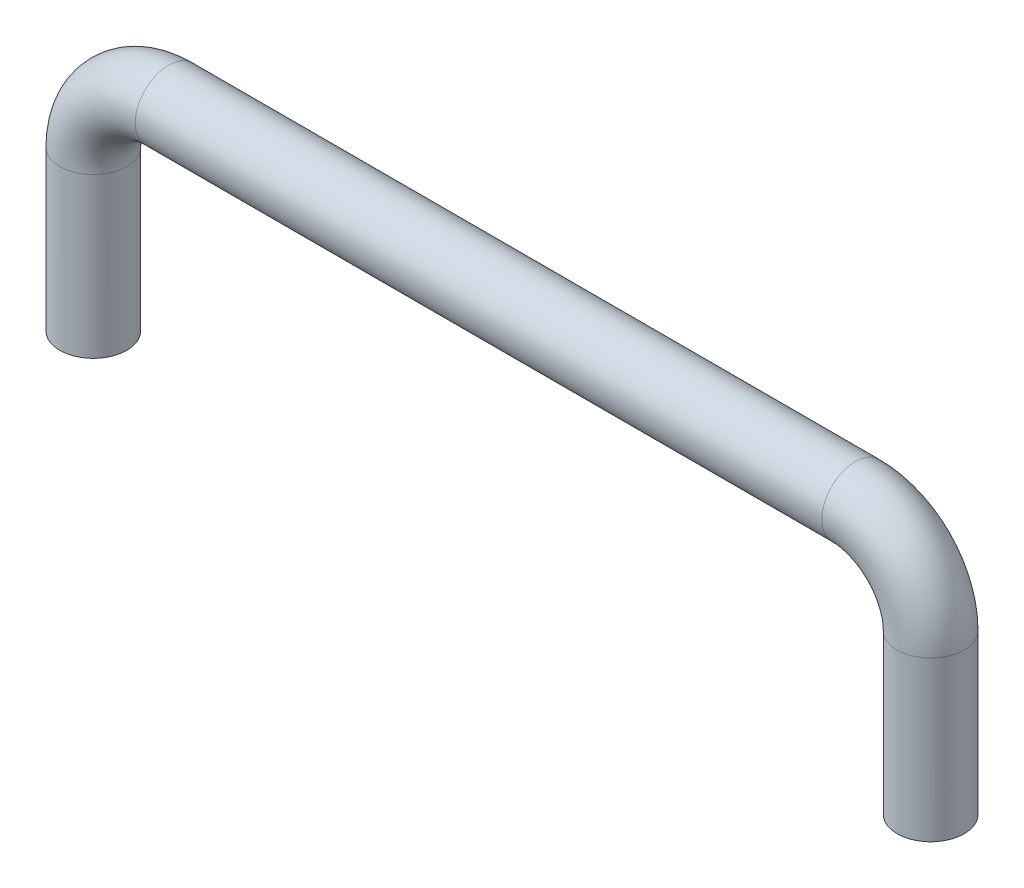
from build123d import *

# Parameters (mm, degrees)
SKETCH2_R = 4


with BuildPart() as part:
    # Sweep1: sweep along a path in Sketch1
    with BuildLine(Plane.XY) as sweep1_path:
        Line((0, 0), (0, 19))
        ThreePointArc((0, 19), (2.636038969, 25.363961031), (9, 28))
        Line((9, 28), (91, 28))
        ThreePointArc((91, 28), (97.363961031, 25.363961031), (100, 19))
        Line((100, 19), (100, 0))
    # Sketch2 → Sweep1 (sweep)
    with BuildSketch(Plane(origin=(0, 0, 0), x_dir=(-1, 0, 0), z_dir=(0, 1, 0))):
        Circle(SKETCH2_R)
    sweep(path=sweep1_path.line)


solid = part.part
